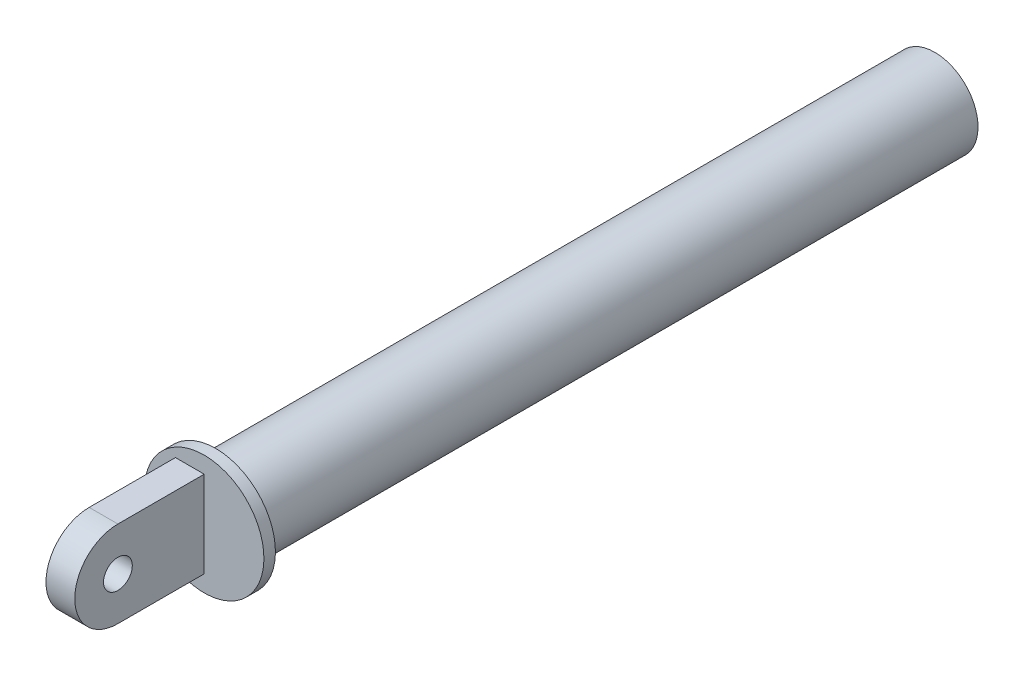
from build123d import *

# Parameters (mm, degrees)
SKETCH1_R           = 5
BOSS_EXTRUDE1_DEPTH = 5


with BuildPart() as part:
    # Sketch1 → Boss-Extrude1 (new body, symmetric)
    with BuildSketch(Plane(origin=(0, 0, 0), x_dir=(0, 0, -1), z_dir=(1, 0, 0))):
        with BuildLine():
            Line((0, 15), (30, 15))
            Line((30, 15), (30, -15))
            Line((30, -15), (0, -15))
            ThreePointArc((0, -15), (-15, 0), (0, 15))
        make_face()
        Circle(SKETCH1_R, mode=Mode.SUBTRACT)
    extrude(amount=BOSS_EXTRUDE1_DEPTH, both=True)

    # Sketch3 → Revolve1 (revolve)
    with BuildSketch(Plane(origin=(5, 0, 0), x_dir=(0, 0, -1), z_dir=(1, 0, 0))):
        Polygon((30, 15), (30, 20.753758682), (33.999504278, 20.753758682), (33.999504278, 15), (283.999504278, 15), (283.999504278, 0), (30, 0), align=None)
    revolve(axis=Axis((5, 0, -283.999504278), (0, 0, 1)))


solid = part.part
